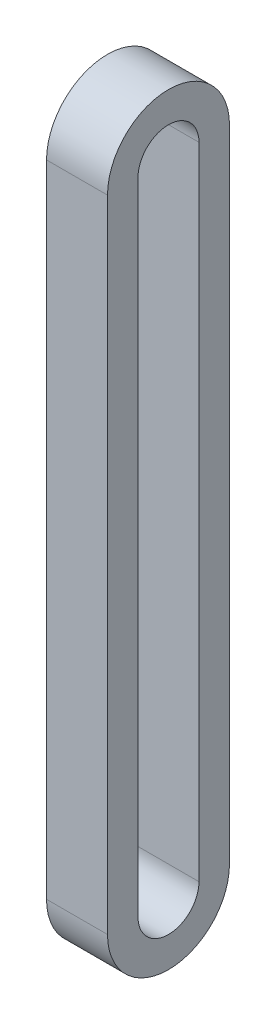
from build123d import *

# Parameters (mm, degrees)
BOSS_EXTRUDE2_DEPTH = 10


with BuildPart() as part:
    # Sketch2 → Boss-Extrude2 (new body)
    with BuildSketch(Plane(origin=(20, 0, 0), x_dir=(0, 0, -1), z_dir=(1, 0, 0))):
        with BuildLine():
            Line((10, 130), (10, 25))
            ThreePointArc((10, 25), (0, 15), (-10, 25))
            Line((-10, 25), (-10, 130))
            ThreePointArc((-10, 130), (0, 140), (10, 130))
        make_face()
        with BuildLine():
            Line((5, 130), (5, 25))
            ThreePointArc((5, 25), (0, 20), (-5, 25))
            Line((-5, 25), (-5, 130))
            ThreePointArc((-5, 130), (0, 135), (5, 130))
        make_face(mode=Mode.SUBTRACT)
    extrude(amount=BOSS_EXTRUDE2_DEPTH)


solid = part.part
